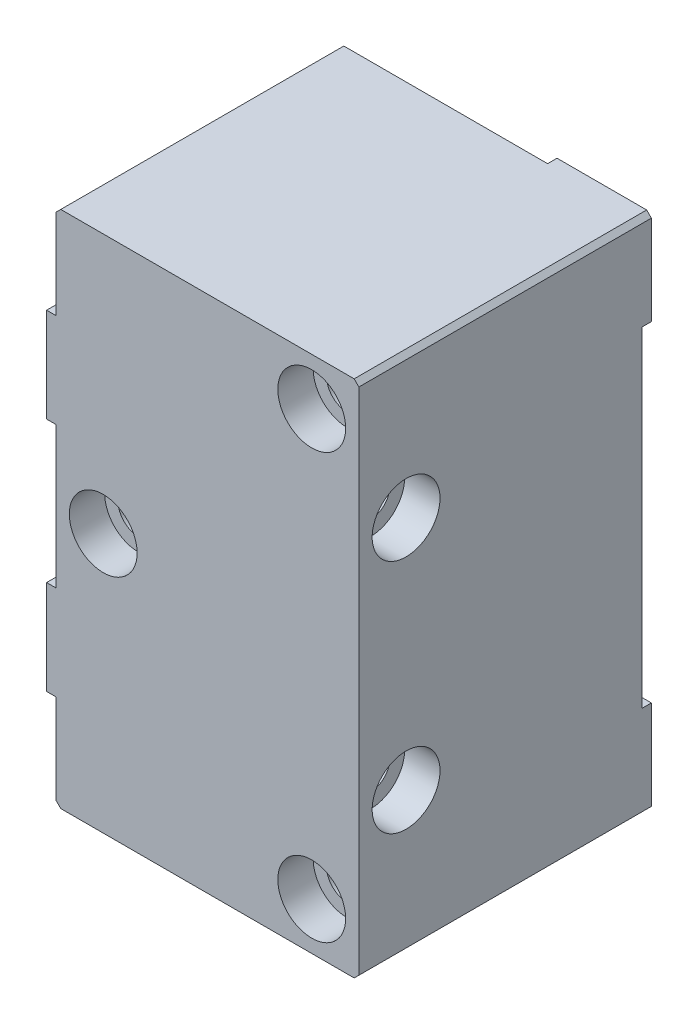
from build123d import *

# Parameters (mm, degrees)
SKETCH1_W                                        = 81.534
SKETCH1_H                                        = 139.7
EXTRUDE1_DEPTH                                   = 76.2
SKETCH8_W                                        = 25.4
SKETCH8_H                                        = 25.4
EXTRUDE2_DEPTH                                   = 2.54
CBORE_FOR_3_8_SOCKET_HEAD_CAP_SCREW1_D           = 11.0998
CBORE_FOR_3_8_SOCKET_HEAD_CAP_SCREW1_CBORE_D     = 18.2626
CBORE_FOR_3_8_SOCKET_HEAD_CAP_SCREW1_CBORE_DEPTH = 9.525
SKETCH9_W                                        = 25.4
SKETCH9_H                                        = 25.4
EXTRUDE3_DEPTH                                   = 2.54
CBORE_FOR_3_8_SOCKET_HEAD_CAP_SCREW3_D           = 10.3124
CBORE_FOR_3_8_SOCKET_HEAD_CAP_SCREW3_CBORE_D     = 18.2626
CBORE_FOR_3_8_SOCKET_HEAD_CAP_SCREW3_CBORE_DEPTH = 9.525
CHAMFER1_SIZE                                    = 1.27


with BuildPart() as part:
    # Sketch1 → Extrude1 (new body)
    with BuildSketch(Plane.XY):
        with Locations((4.098167124, -35.572612746)):
            Rectangle(SKETCH1_W, SKETCH1_H)
    extrude(amount=EXTRUDE1_DEPTH)

    # Sketch8 → Extrude2 (add)
    with BuildSketch(Plane(origin=(0, 0, 0), x_dir=(-1, 0, 0), z_dir=(0, 0, -1))):
        with Locations((-32.165167124, -92.722612746)):
            Rectangle(SKETCH8_W, SKETCH8_H)
        with Locations((-32.165167124, 21.577387254)):
            Rectangle(SKETCH8_W, SKETCH8_H)
        with Locations((23.968832876, -35.572612746)):
            Rectangle(SKETCH8_W, SKETCH8_H)
    extrude(amount=EXTRUDE2_DEPTH)

    # CBORE for 3/8 Socket Head Cap Screw1 (through all)
    with Locations(Plane.XY.offset(76.2)):
        with Locations((-23.968832876, -35.572612746), (32.165167124, 21.577387254), (32.165167124, -92.722612746)):
            CounterBoreHole(CBORE_FOR_3_8_SOCKET_HEAD_CAP_SCREW1_D / 2, CBORE_FOR_3_8_SOCKET_HEAD_CAP_SCREW1_CBORE_D / 2, CBORE_FOR_3_8_SOCKET_HEAD_CAP_SCREW1_CBORE_DEPTH)

    # Sketch9 → Extrude3 (add)
    with BuildSketch(Plane.ZY.offset(36.668832876)):
        with Locations((63.5, -3.822612746)):
            Rectangle(SKETCH9_W, SKETCH9_H)
        with Locations((63.5, -67.322612746)):
            Rectangle(SKETCH9_W, SKETCH9_H)
    extrude(amount=EXTRUDE3_DEPTH)

    # CBORE for 3/8 Socket Head Cap Screw3 (through all)
    with Locations(Plane(origin=(44.865167124, 0, 0), x_dir=(0, 0, -1), z_dir=(1, 0, 0))):
        with Locations((-63.5, -3.822612746), (-63.5, -67.322612746)):
            CounterBoreHole(CBORE_FOR_3_8_SOCKET_HEAD_CAP_SCREW3_D / 2, CBORE_FOR_3_8_SOCKET_HEAD_CAP_SCREW3_CBORE_D / 2, CBORE_FOR_3_8_SOCKET_HEAD_CAP_SCREW3_CBORE_DEPTH)

    # Chamfer1
    chamfer1_edges = [part.edges().sort_by_distance(p)[0] for p in [
        (44.865167124, 34.277387254, 36.83),
        (-36.668832876, 34.277387254, 38.1),
        (44.865167124, -105.422612746, 36.83),
        (-36.668832876, -105.422612746, 38.1),
    ]]
    chamfer(chamfer1_edges, length=CHAMFER1_SIZE)


solid = part.part
